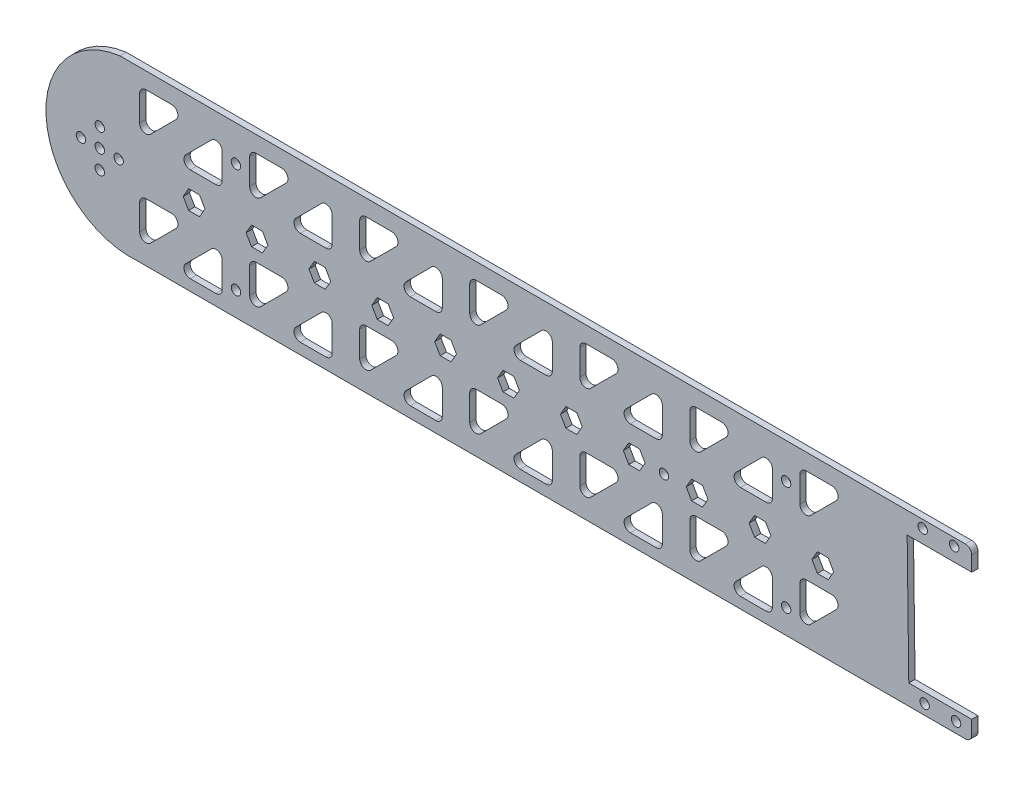
from build123d import *

# Parameters (mm, degrees)
IZIM1_R                     = 1.5
Y_KSEKLIK_EKSTR_ZYON2_DEPTH = 2
IZIM9_R                     = 1.5
KES_EKSTR_ZYON5_DEPTH       = 10
IZIM10_R                    = 1.5
KES_EKSTR_ZYON7_DEPTH       = 10


with BuildPart() as part:
    # Çizim1 → Yükseklik-Ekstrüzyon2 (new body)
    with BuildSketch(Plane.XY):
        with BuildLine():
            ThreePointArc((-123.68208832, 28.6803889), (-147.097650837, -0.85979795), (-118.162671893, -25.019230903))
            Line((-118.162671893, -25.019230903), (145.239149777, -25.019230903))
            ThreePointArc((145.239149777, -25.019230903), (146.65336334, -24.433444465), (147.239149777, -23.019230903))
            Line((147.239149777, -23.019230903), (147.239149777, -18.615828672))
            Line((147.239149777, -18.615828672), (127.222621818, -18.615828672))
            Line((127.222621818, -18.615828672), (126.706405407, 21.900803601))
            Line((126.706405407, 21.900803601), (147.239149777, 21.900803601))
            Line((147.239149777, 21.900803601), (147.239149777, 26.6803889))
            ThreePointArc((147.239149777, 26.6803889), (146.65336334, 28.094602463), (145.239149777, 28.6803889))
            Line((145.239149777, 28.6803889), (-123.68208832, 28.6803889))
        make_face()
        with BuildLine():
            Line((-117.432950192, -16.684982837), (-117.432950192, -8.513409962))
            ThreePointArc((-117.432950192, -8.513409962), (-116.847163754, -7.099196399), (-115.432950192, -6.513409962))
            Line((-115.432950192, -6.513409962), (-107.261377316, -6.513409962))
            ThreePointArc((-107.261377316, -6.513409962), (-105.413618251, -7.748043097), (-105.847163754, -9.927623524))
            Line((-105.847163754, -9.927623524), (-114.018736629, -18.099196399))
            ThreePointArc((-114.018736629, -18.099196399), (-116.198317056, -18.532741902), (-117.432950192, -16.684982837))
        make_face(mode=Mode.SUBTRACT)
        with BuildLine():
            Line((-102.756511954, -18.099196399), (-94.584939079, -9.927623524))
            ThreePointArc((-94.584939079, -9.927623524), (-92.405358652, -9.494078021), (-91.170725517, -11.341837086))
            Line((-91.170725517, -11.341837086), (-91.170725517, -19.513409962))
            ThreePointArc((-91.170725517, -19.513409962), (-91.756511954, -20.927623524), (-93.170725517, -21.513409962))
            Line((-93.170725517, -21.513409962), (-101.342298392, -21.513409962))
            ThreePointArc((-101.342298392, -21.513409962), (-103.190057457, -20.278776826), (-102.756511954, -18.099196399))
        make_face(mode=Mode.SUBTRACT)
        with BuildLine():
            Line((-82.432950192, -16.684982837), (-82.432950192, -8.513409962))
            ThreePointArc((-82.432950192, -8.513409962), (-81.847163754, -7.099196399), (-80.432950192, -6.513409962))
            Line((-80.432950192, -6.513409962), (-72.261377316, -6.513409962))
            ThreePointArc((-72.261377316, -6.513409962), (-70.413618251, -7.748043097), (-70.847163754, -9.927623524))
            Line((-70.847163754, -9.927623524), (-79.018736629, -18.099196399))
            ThreePointArc((-79.018736629, -18.099196399), (-81.198317056, -18.532741902), (-82.432950192, -16.684982837))
        make_face(mode=Mode.SUBTRACT)
        with BuildLine():
            Line((-67.756511954, -18.099196399), (-59.584939079, -9.927623524))
            ThreePointArc((-59.584939079, -9.927623524), (-57.405358652, -9.494078021), (-56.170725517, -11.341837086))
            Line((-56.170725517, -11.341837086), (-56.170725517, -19.513409962))
            ThreePointArc((-56.170725517, -19.513409962), (-56.756511954, -20.927623524), (-58.170725517, -21.513409962))
            Line((-58.170725517, -21.513409962), (-66.342298392, -21.513409962))
            ThreePointArc((-66.342298392, -21.513409962), (-68.190057457, -20.278776826), (-67.756511954, -18.099196399))
        make_face(mode=Mode.SUBTRACT)
        with BuildLine():
            Line((-47.432950192, -16.684982837), (-47.432950192, -8.513409962))
            ThreePointArc((-47.432950192, -8.513409962), (-46.847163754, -7.099196399), (-45.432950192, -6.513409962))
            Line((-45.432950192, -6.513409962), (-37.261377316, -6.513409962))
            ThreePointArc((-37.261377316, -6.513409962), (-35.413618251, -7.748043097), (-35.847163754, -9.927623524))
            Line((-35.847163754, -9.927623524), (-44.018736629, -18.099196399))
            ThreePointArc((-44.018736629, -18.099196399), (-46.198317056, -18.532741902), (-47.432950192, -16.684982837))
        make_face(mode=Mode.SUBTRACT)
        with BuildLine():
            Line((-32.756511954, -18.099196399), (-24.584939079, -9.927623524))
            ThreePointArc((-24.584939079, -9.927623524), (-22.405358652, -9.494078021), (-21.170725517, -11.341837086))
            Line((-21.170725517, -11.341837086), (-21.170725517, -19.513409962))
            ThreePointArc((-21.170725517, -19.513409962), (-21.756511954, -20.927623524), (-23.170725517, -21.513409962))
            Line((-23.170725517, -21.513409962), (-31.342298392, -21.513409962))
            ThreePointArc((-31.342298392, -21.513409962), (-33.190057457, -20.278776826), (-32.756511954, -18.099196399))
        make_face(mode=Mode.SUBTRACT)
        with BuildLine():
            Line((-12.432950192, -16.684982837), (-12.432950192, -8.513409962))
            ThreePointArc((-12.432950192, -8.513409962), (-11.847163754, -7.099196399), (-10.432950192, -6.513409962))
            Line((-10.432950192, -6.513409962), (-2.261377316, -6.513409962))
            ThreePointArc((-2.261377316, -6.513409962), (-0.413618251, -7.748043097), (-0.847163754, -9.927623524))
            Line((-0.847163754, -9.927623524), (-9.018736629, -18.099196399))
            ThreePointArc((-9.018736629, -18.099196399), (-11.198317056, -18.532741902), (-12.432950192, -16.684982837))
        make_face(mode=Mode.SUBTRACT)
        Polygon((-96.652716692, 0.01885212), (-98.388672632, -2.978889859), (-101.85277131, -2.974378905), (-103.580914048, 0.027874028), (-101.844958108, 3.025616007), (-98.38085943, 3.021105053), align=None, mode=Mode.SUBTRACT)
        Polygon((-76.652716692, 0.01885212), (-78.388672632, -2.978889859), (-81.85277131, -2.974378905), (-83.580914048, 0.027874028), (-81.844958108, 3.025616007), (-78.38085943, 3.021105053), align=None, mode=Mode.SUBTRACT)
        Polygon((-56.652716692, 0.01885212), (-58.388672632, -2.978889859), (-61.85277131, -2.974378905), (-63.580914048, 0.027874028), (-61.844958108, 3.025616007), (-58.38085943, 3.021105053), align=None, mode=Mode.SUBTRACT)
        Polygon((-36.652716692, 0.01885212), (-38.388672632, -2.978889859), (-41.85277131, -2.974378905), (-43.580914048, 0.027874028), (-41.844958108, 3.025616007), (-38.38085943, 3.021105053), align=None, mode=Mode.SUBTRACT)
        Polygon((-16.652716692, 0.01885212), (-18.388672632, -2.978889859), (-21.85277131, -2.974378905), (-23.580914048, 0.027874028), (-21.844958108, 3.025616007), (-18.38085943, 3.021105053), align=None, mode=Mode.SUBTRACT)
        Polygon((3.347283308, 0.01885212), (1.611327368, -2.978889859), (-1.85277131, -2.974378905), (-3.580914048, 0.027874028), (-1.844958108, 3.025616007), (1.61914057, 3.021105053), align=None, mode=Mode.SUBTRACT)
        with BuildLine():
            Line((2.243488046, -18.099196399), (10.415060921, -9.927623524))
            ThreePointArc((10.415060921, -9.927623524), (12.594641348, -9.494078021), (13.829274483, -11.341837086))
            Line((13.829274483, -11.341837086), (13.829274483, -19.513409962))
            ThreePointArc((13.829274483, -19.513409962), (13.243488046, -20.927623524), (11.829274483, -21.513409962))
            Line((11.829274483, -21.513409962), (3.657701608, -21.513409962))
            ThreePointArc((3.657701608, -21.513409962), (1.809942543, -20.278776826), (2.243488046, -18.099196399))
        make_face(mode=Mode.SUBTRACT)
        with BuildLine():
            Line((22.567049808, -16.684982837), (22.567049808, -8.513409962))
            ThreePointArc((22.567049808, -8.513409962), (23.152836246, -7.099196399), (24.567049808, -6.513409962))
            Line((24.567049808, -6.513409962), (32.738622684, -6.513409962))
            ThreePointArc((32.738622684, -6.513409962), (34.586381749, -7.748043097), (34.152836246, -9.927623524))
            Line((34.152836246, -9.927623524), (25.981263371, -18.099196399))
            ThreePointArc((25.981263371, -18.099196399), (23.801682944, -18.532741902), (22.567049808, -16.684982837))
        make_face(mode=Mode.SUBTRACT)
        with BuildLine():
            Line((37.243488046, -18.099196399), (45.415060921, -9.927623524))
            ThreePointArc((45.415060921, -9.927623524), (47.594641348, -9.494078021), (48.829274483, -11.341837086))
            Line((48.829274483, -11.341837086), (48.829274483, -19.513409962))
            ThreePointArc((48.829274483, -19.513409962), (48.243488046, -20.927623524), (46.829274483, -21.513409962))
            Line((46.829274483, -21.513409962), (38.657701608, -21.513409962))
            ThreePointArc((38.657701608, -21.513409962), (36.809942543, -20.278776826), (37.243488046, -18.099196399))
        make_face(mode=Mode.SUBTRACT)
        with BuildLine():
            Line((57.567049808, -16.684982837), (57.567049808, -8.513409962))
            ThreePointArc((57.567049808, -8.513409962), (58.152836246, -7.099196399), (59.567049808, -6.513409962))
            Line((59.567049808, -6.513409962), (67.738622684, -6.513409962))
            ThreePointArc((67.738622684, -6.513409962), (69.586381749, -7.748043097), (69.152836246, -9.927623524))
            Line((69.152836246, -9.927623524), (60.981263371, -18.099196399))
            ThreePointArc((60.981263371, -18.099196399), (58.801682944, -18.532741902), (57.567049808, -16.684982837))
        make_face(mode=Mode.SUBTRACT)
        with Locations((132.263518882, -21.793893793)):
            Circle(IZIM1_R, mode=Mode.SUBTRACT)
        with Locations((142.262707334, -21.666495614)):
            Circle(IZIM1_R, mode=Mode.SUBTRACT)
        with BuildLine():
            Line((72.243488046, -18.099196399), (80.415060921, -9.927623524))
            ThreePointArc((80.415060921, -9.927623524), (82.594641348, -9.494078021), (83.829274483, -11.341837086))
            Line((83.829274483, -11.341837086), (83.829274483, -19.513409962))
            ThreePointArc((83.829274483, -19.513409962), (83.243488046, -20.927623524), (81.829274483, -21.513409962))
            Line((81.829274483, -21.513409962), (73.657701608, -21.513409962))
            ThreePointArc((73.657701608, -21.513409962), (71.809942543, -20.278776826), (72.243488046, -18.099196399))
        make_face(mode=Mode.SUBTRACT)
        with BuildLine():
            Line((92.567049808, -16.684982837), (92.567049808, -8.513409962))
            ThreePointArc((92.567049808, -8.513409962), (93.152836246, -7.099196399), (94.567049808, -6.513409962))
            Line((94.567049808, -6.513409962), (102.738622684, -6.513409962))
            ThreePointArc((102.738622684, -6.513409962), (104.586381749, -7.748043097), (104.152836246, -9.927623524))
            Line((104.152836246, -9.927623524), (95.981263371, -18.099196399))
            ThreePointArc((95.981263371, -18.099196399), (93.801682944, -18.532741902), (92.567049808, -16.684982837))
        make_face(mode=Mode.SUBTRACT)
        Polygon((23.347283308, 0.01885212), (21.611327368, -2.978889859), (18.14722869, -2.974378905), (16.419085952, 0.027874028), (18.155041892, 3.025616007), (21.61914057, 3.021105053), align=None, mode=Mode.SUBTRACT)
        Polygon((43.347283308, 0.01885212), (41.611327368, -2.978889859), (38.14722869, -2.974378905), (36.419085952, 0.027874028), (38.155041892, 3.025616007), (41.61914057, 3.021105053), align=None, mode=Mode.SUBTRACT)
        Polygon((63.347283308, 0.01885212), (61.611327368, -2.978889859), (58.14722869, -2.974378905), (56.419085952, 0.027874028), (58.155041892, 3.025616007), (61.61914057, 3.021105053), align=None, mode=Mode.SUBTRACT)
        Polygon((83.347283308, 0.01885212), (81.611327368, -2.978889859), (78.14722869, -2.974378905), (76.419085952, 0.027874028), (78.155041892, 3.025616007), (81.61914057, 3.021105053), align=None, mode=Mode.SUBTRACT)
        Polygon((103.347283308, 0.01885212), (101.611327368, -2.978889859), (98.14722869, -2.974378905), (96.419085952, 0.027874028), (98.155041892, 3.025616007), (101.61914057, 3.021105053), align=None, mode=Mode.SUBTRACT)
        with BuildLine():
            Line((-102.756511954, 11.900803601), (-94.584939079, 20.072376476))
            ThreePointArc((-94.584939079, 20.072376476), (-92.405358652, 20.505921979), (-91.170725517, 18.658162914))
            Line((-91.170725517, 18.658162914), (-91.170725517, 10.486590038))
            ThreePointArc((-91.170725517, 10.486590038), (-91.756511954, 9.072376476), (-93.170725517, 8.486590038))
            Line((-93.170725517, 8.486590038), (-101.342298392, 8.486590038))
            ThreePointArc((-101.342298392, 8.486590038), (-103.190057457, 9.721223174), (-102.756511954, 11.900803601))
        make_face(mode=Mode.SUBTRACT)
        with BuildLine():
            Line((-67.756511954, 11.900803601), (-59.584939079, 20.072376476))
            ThreePointArc((-59.584939079, 20.072376476), (-57.405358652, 20.505921979), (-56.170725517, 18.658162914))
            Line((-56.170725517, 18.658162914), (-56.170725517, 10.486590038))
            ThreePointArc((-56.170725517, 10.486590038), (-56.756511954, 9.072376476), (-58.170725517, 8.486590038))
            Line((-58.170725517, 8.486590038), (-66.342298392, 8.486590038))
            ThreePointArc((-66.342298392, 8.486590038), (-68.190057457, 9.721223174), (-67.756511954, 11.900803601))
        make_face(mode=Mode.SUBTRACT)
        with BuildLine():
            Line((-32.756511954, 11.900803601), (-24.584939079, 20.072376476))
            ThreePointArc((-24.584939079, 20.072376476), (-22.405358652, 20.505921979), (-21.170725517, 18.658162914))
            Line((-21.170725517, 18.658162914), (-21.170725517, 10.486590038))
            ThreePointArc((-21.170725517, 10.486590038), (-21.756511954, 9.072376476), (-23.170725517, 8.486590038))
            Line((-23.170725517, 8.486590038), (-31.342298392, 8.486590038))
            ThreePointArc((-31.342298392, 8.486590038), (-33.190057457, 9.721223174), (-32.756511954, 11.900803601))
        make_face(mode=Mode.SUBTRACT)
        with BuildLine():
            Line((-117.432950192, 13.315017163), (-117.432950192, 21.486590038))
            ThreePointArc((-117.432950192, 21.486590038), (-116.847163754, 22.900803601), (-115.432950192, 23.486590038))
            Line((-115.432950192, 23.486590038), (-107.261377316, 23.486590038))
            ThreePointArc((-107.261377316, 23.486590038), (-105.413618251, 22.251956903), (-105.847163754, 20.072376476))
            Line((-105.847163754, 20.072376476), (-114.018736629, 11.900803601))
            ThreePointArc((-114.018736629, 11.900803601), (-116.198317056, 11.467258098), (-117.432950192, 13.315017163))
        make_face(mode=Mode.SUBTRACT)
        with BuildLine():
            Line((-82.432950192, 13.315017163), (-82.432950192, 21.486590038))
            ThreePointArc((-82.432950192, 21.486590038), (-81.847163754, 22.900803601), (-80.432950192, 23.486590038))
            Line((-80.432950192, 23.486590038), (-72.261377316, 23.486590038))
            ThreePointArc((-72.261377316, 23.486590038), (-70.413618251, 22.251956903), (-70.847163754, 20.072376476))
            Line((-70.847163754, 20.072376476), (-79.018736629, 11.900803601))
            ThreePointArc((-79.018736629, 11.900803601), (-81.198317056, 11.467258098), (-82.432950192, 13.315017163))
        make_face(mode=Mode.SUBTRACT)
        with BuildLine():
            Line((-47.432950192, 13.315017163), (-47.432950192, 21.486590038))
            ThreePointArc((-47.432950192, 21.486590038), (-46.847163754, 22.900803601), (-45.432950192, 23.486590038))
            Line((-45.432950192, 23.486590038), (-37.261377316, 23.486590038))
            ThreePointArc((-37.261377316, 23.486590038), (-35.413618251, 22.251956903), (-35.847163754, 20.072376476))
            Line((-35.847163754, 20.072376476), (-44.018736629, 11.900803601))
            ThreePointArc((-44.018736629, 11.900803601), (-46.198317056, 11.467258098), (-47.432950192, 13.315017163))
        make_face(mode=Mode.SUBTRACT)
        with BuildLine():
            Line((-12.432950192, 13.315017163), (-12.432950192, 21.486590038))
            ThreePointArc((-12.432950192, 21.486590038), (-11.847163754, 22.900803601), (-10.432950192, 23.486590038))
            Line((-10.432950192, 23.486590038), (-2.261377316, 23.486590038))
            ThreePointArc((-2.261377316, 23.486590038), (-0.413618251, 22.251956903), (-0.847163754, 20.072376476))
            Line((-0.847163754, 20.072376476), (-9.018736629, 11.900803601))
            ThreePointArc((-9.018736629, 11.900803601), (-11.198317056, 11.467258098), (-12.432950192, 13.315017163))
        make_face(mode=Mode.SUBTRACT)
        with BuildLine():
            Line((2.243488046, 11.900803601), (10.415060921, 20.072376476))
            ThreePointArc((10.415060921, 20.072376476), (12.594641348, 20.505921979), (13.829274483, 18.658162914))
            Line((13.829274483, 18.658162914), (13.829274483, 10.486590038))
            ThreePointArc((13.829274483, 10.486590038), (13.243488046, 9.072376476), (11.829274483, 8.486590038))
            Line((11.829274483, 8.486590038), (3.657701608, 8.486590038))
            ThreePointArc((3.657701608, 8.486590038), (1.809942543, 9.721223174), (2.243488046, 11.900803601))
        make_face(mode=Mode.SUBTRACT)
        with BuildLine():
            Line((37.243488046, 11.900803601), (45.415060921, 20.072376476))
            ThreePointArc((45.415060921, 20.072376476), (47.594641348, 20.505921979), (48.829274483, 18.658162914))
            Line((48.829274483, 18.658162914), (48.829274483, 10.486590038))
            ThreePointArc((48.829274483, 10.486590038), (48.243488046, 9.072376476), (46.829274483, 8.486590038))
            Line((46.829274483, 8.486590038), (38.657701608, 8.486590038))
            ThreePointArc((38.657701608, 8.486590038), (36.809942543, 9.721223174), (37.243488046, 11.900803601))
        make_face(mode=Mode.SUBTRACT)
        with BuildLine():
            Line((72.243488046, 11.900803601), (80.415060921, 20.072376476))
            ThreePointArc((80.415060921, 20.072376476), (82.594641348, 20.505921979), (83.829274483, 18.658162914))
            Line((83.829274483, 18.658162914), (83.829274483, 10.486590038))
            ThreePointArc((83.829274483, 10.486590038), (83.243488046, 9.072376476), (81.829274483, 8.486590038))
            Line((81.829274483, 8.486590038), (73.657701608, 8.486590038))
            ThreePointArc((73.657701608, 8.486590038), (71.809942543, 9.721223174), (72.243488046, 11.900803601))
        make_face(mode=Mode.SUBTRACT)
        with BuildLine():
            Line((22.567049808, 13.315017163), (22.567049808, 21.486590038))
            ThreePointArc((22.567049808, 21.486590038), (23.152836246, 22.900803601), (24.567049808, 23.486590038))
            Line((24.567049808, 23.486590038), (32.738622684, 23.486590038))
            ThreePointArc((32.738622684, 23.486590038), (34.586381749, 22.251956903), (34.152836246, 20.072376476))
            Line((34.152836246, 20.072376476), (25.981263371, 11.900803601))
            ThreePointArc((25.981263371, 11.900803601), (23.801682944, 11.467258098), (22.567049808, 13.315017163))
        make_face(mode=Mode.SUBTRACT)
        with BuildLine():
            Line((57.567049808, 13.315017163), (57.567049808, 21.486590038))
            ThreePointArc((57.567049808, 21.486590038), (58.152836246, 22.900803601), (59.567049808, 23.486590038))
            Line((59.567049808, 23.486590038), (67.738622684, 23.486590038))
            ThreePointArc((67.738622684, 23.486590038), (69.586381749, 22.251956903), (69.152836246, 20.072376476))
            Line((69.152836246, 20.072376476), (60.981263371, 11.900803601))
            ThreePointArc((60.981263371, 11.900803601), (58.801682944, 11.467258098), (57.567049808, 13.315017163))
        make_face(mode=Mode.SUBTRACT)
        with BuildLine():
            Line((92.567049808, 13.315017163), (92.567049808, 21.486590038))
            ThreePointArc((92.567049808, 21.486590038), (93.152836246, 22.900803601), (94.567049808, 23.486590038))
            Line((94.567049808, 23.486590038), (102.738622684, 23.486590038))
            ThreePointArc((102.738622684, 23.486590038), (104.586381749, 22.251956903), (104.152836246, 20.072376476))
            Line((104.152836246, 20.072376476), (95.981263371, 11.900803601))
            ThreePointArc((95.981263371, 11.900803601), (93.801682944, 11.467258098), (92.567049808, 13.315017163))
        make_face(mode=Mode.SUBTRACT)
        with Locations((131.652007622, 26.202210778)):
            Circle(IZIM1_R, mode=Mode.SUBTRACT)
        with Locations((141.651196074, 26.329608957)):
            Circle(IZIM1_R, mode=Mode.SUBTRACT)
        with Locations((-130.106258095, 6.023363074)):
            Circle(IZIM1_R, mode=Mode.SUBTRACT)
        with Locations((-130.106258095, -5.976636926)):
            Circle(IZIM1_R, mode=Mode.SUBTRACT)
        with Locations((-136.106258095, 0.023363074)):
            Circle(IZIM1_R, mode=Mode.SUBTRACT)
        with Locations((-130.106258095, 0.023363074)):
            Circle(IZIM1_R, mode=Mode.SUBTRACT)
        with Locations((-124.106258095, 0.023363074)):
            Circle(IZIM1_R, mode=Mode.SUBTRACT)
    extrude(amount=Y_KSEKLIK_EKSTR_ZYON2_DEPTH)

    # Çizim9 → Kes-Ekstrüzyon5 (cut)
    with BuildSketch(Plane(origin=(0, 0, 0), x_dir=(-1, 0, 0), z_dir=(0, 0, -1))):
        with Locations((-88.198162146, 17.400803601)):
            Circle(IZIM9_R)
        with Locations((-88.222150893, -17.356386837)):
            Circle(IZIM9_R)
        with Locations((86.801837854, 17.400803601)):
            Circle(IZIM9_R)
        with Locations((86.777849107, -17.356386837)):
            Circle(IZIM9_R)
    extrude(amount=-KES_EKSTR_ZYON5_DEPTH, mode=Mode.SUBTRACT)

    # Çizim10 → Kes-Ekstrüzyon7 (cut)
    with BuildSketch(Plane.XY.offset(2)):
        with Locations((49.347283308, 0)):
            Circle(IZIM10_R)
    extrude(amount=-KES_EKSTR_ZYON7_DEPTH, mode=Mode.SUBTRACT)


solid = part.part
